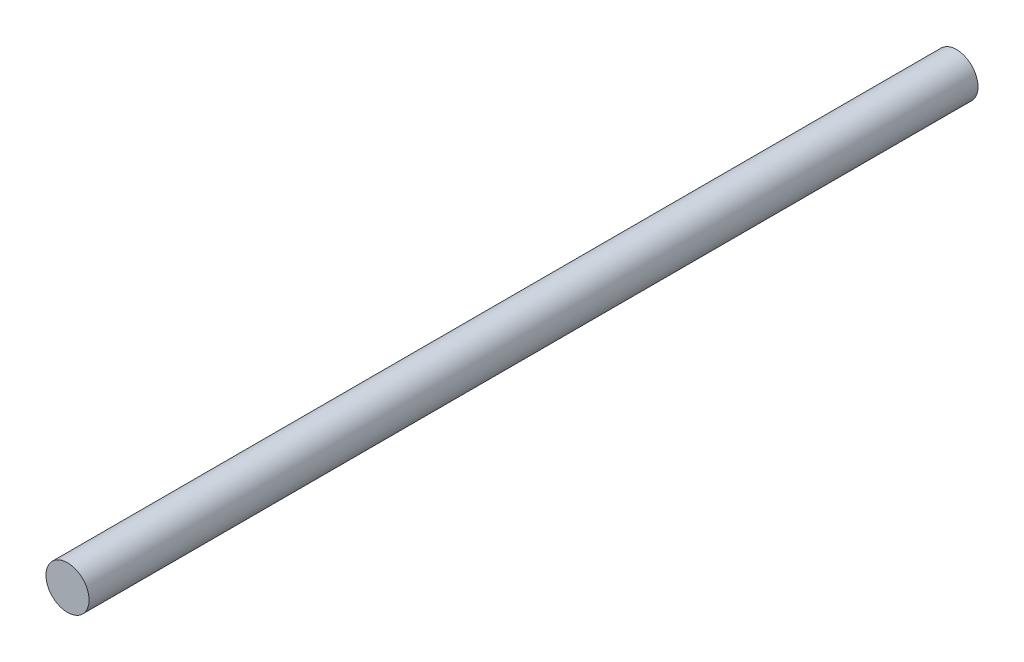
from build123d import *

# Parameters (mm, degrees)
SKETCH_3_R      = 4
EXTRUDE_1_DEPTH = 82.5


with BuildPart() as part:
    # 草图3 → 凸台-拉伸1 (new body, symmetric)
    with BuildSketch(Plane.XY):
        Circle(SKETCH_3_R)
    extrude(amount=EXTRUDE_1_DEPTH, both=True)


solid = part.part
